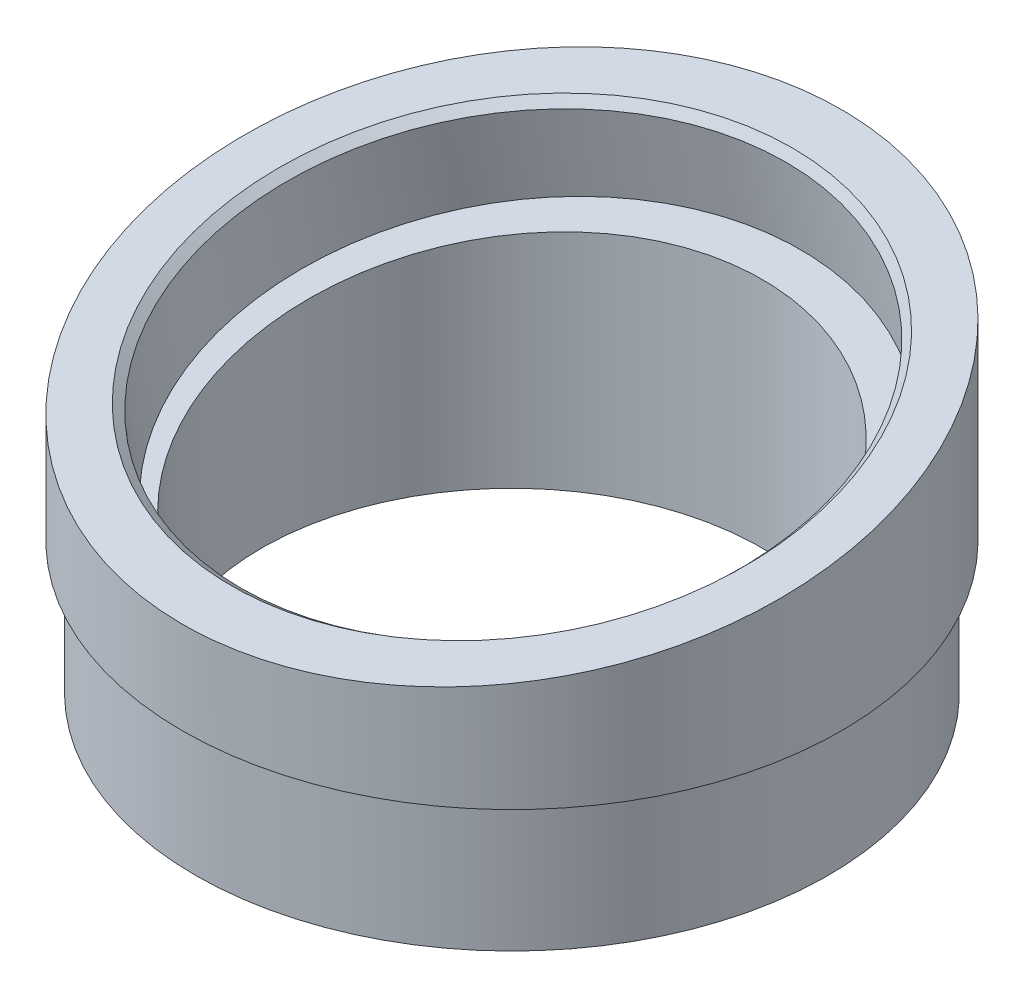
from build123d import *

# Parameters (mm, degrees)
SKETCH_1_R          = 24
SKETCH_1_R_2        = 19
EXTRUDE_1_DEPTH     = 10
SKETCH_2_R          = 25
SKETCH_2_R_2        = 19
EXTRUDE_2_DEPTH     = 20
CUT_EXTRUDE_1_DEPTH = 31
SKETCH_4_R          = 21
CUT_EXTRUDE_2_DEPTH = 7
CHAMFER_1_SIZE      = 0.6


with BuildPart() as part:
    # 草图1 → 凸台-拉伸1 (new body)
    with BuildSketch(Plane(origin=(0, 0, 0), x_dir=(1, 0, 0), z_dir=(0, 1, 0))):
        Circle(SKETCH_1_R)
        Circle(SKETCH_1_R_2, mode=Mode.SUBTRACT)
    extrude(amount=EXTRUDE_1_DEPTH)

    # 草图2 → 凸台-拉伸2 (add)
    with BuildSketch(Plane(origin=(0, 10, 0), x_dir=(1, 0, 0), z_dir=(0, 1, 0))):
        Circle(SKETCH_2_R)
        Circle(SKETCH_2_R_2, mode=Mode.SUBTRACT)
    extrude(amount=EXTRUDE_2_DEPTH)

    # 草图3 → 切除-拉伸1 (cut, symmetric)
    with BuildSketch(Plane(origin=(0, 0, 0), x_dir=(0, 0, -1), z_dir=(1, 0, 0))):
        Polygon((-25, 17), (25, 25.816349035), (25, 47.879470908), (-25, 47.879470908), align=None)
    extrude(amount=CUT_EXTRUDE_1_DEPTH, both=True, mode=Mode.SUBTRACT)

    # 草图4 → 切除-拉伸2 (cut)
    with BuildSketch(Plane(origin=(0, 20.762639068, 3.661013458), x_dir=(1, 0, 0), z_dir=(0, 0.984807753, 0.173648178))):
        with Locations((0, 3.717490492)):
            Circle(SKETCH_4_R)
    extrude(amount=-CUT_EXTRUDE_2_DEPTH, mode=Mode.SUBTRACT)

    # 倒角1
    chamfer_1_edges = [part.edges().sort_by_distance(p)[0] for p in [
        (-21, 21.408174518, 0),
    ]]
    chamfer(chamfer_1_edges, length=CHAMFER_1_SIZE)


solid = part.part
